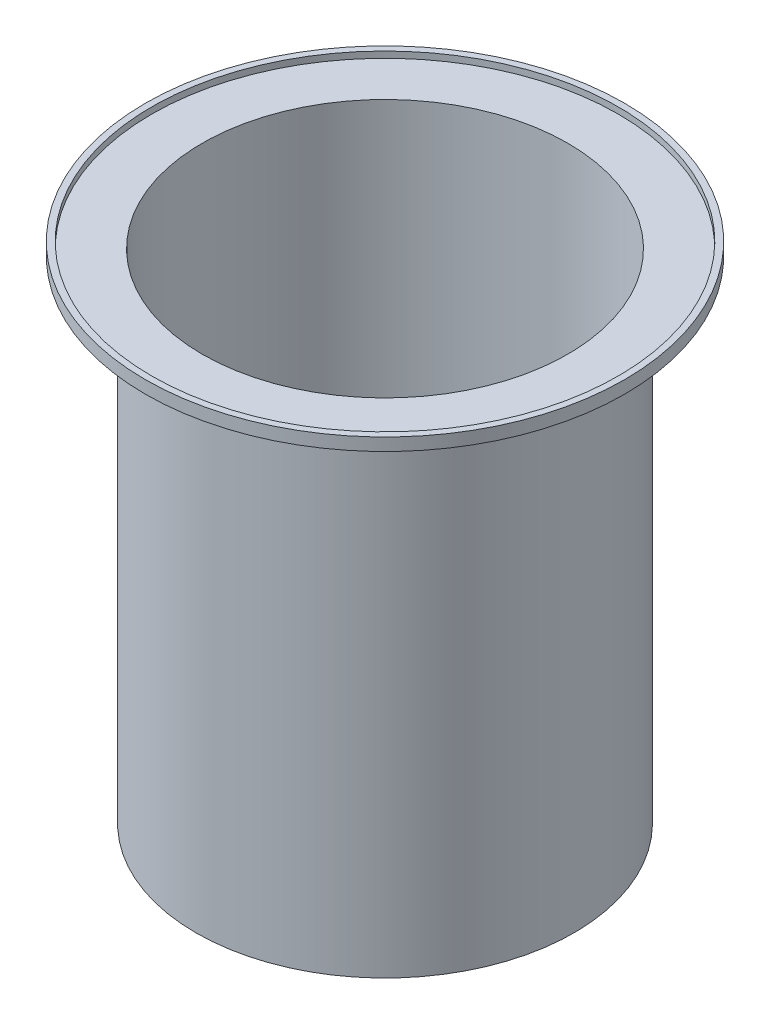
from build123d import *

# Parameters (mm, degrees)
SHELL1_T = -5


with BuildPart() as part:
    # Sketch1 → Revolve1 (revolve)
    with BuildSketch(Plane(origin=(0, 0, 0), x_dir=(0, 0, -1), z_dir=(1, 0, 0))):
        Polygon((0, 329.971145898), (0, -70.028854102), (-150, -70.028854102), (-150, 319.971145898), (-190, 319.971145898), (-190, 329.971145898), align=None)
    revolve(axis=Axis((0, 438.369922809, 0), (0, -1, 0)))

    # Shell1
    shell1_openings = [part.faces().sort_by_distance(p)[0] for p in [
        (0, 329.971145898, 0),
    ]]
    offset(amount=SHELL1_T, openings=shell1_openings, kind=Kind.INTERSECTION)


solid = part.part
